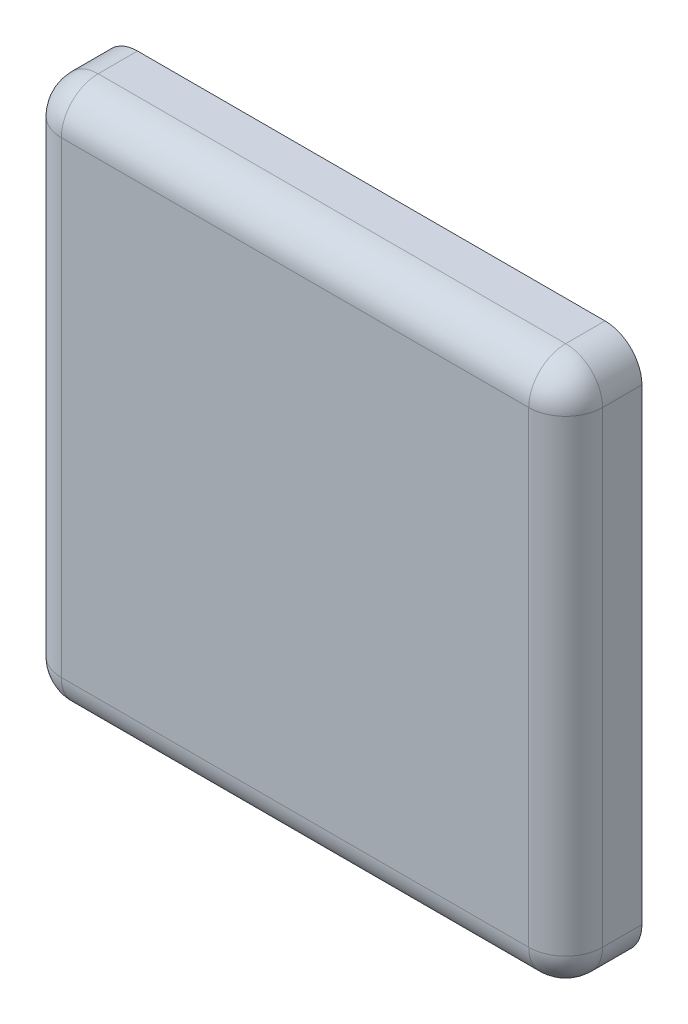
from build123d import *

# Parameters (mm, degrees)
SKETCH1_W      = 22
SKETCH1_H      = 22
EXTRUDE1_DEPTH = 3.1
FILLET1_R      = 1.5


with BuildPart() as part:
    # Sketch1 → Extrude1 (new body)
    with BuildSketch(Plane.XY):
        with Locations((11, 11)):
            Rectangle(SKETCH1_W, SKETCH1_H)
    extrude(amount=EXTRUDE1_DEPTH)

    # Fillet1
    fillet1_edges = [part.edges().sort_by_distance(p)[0] for p in [
        (22, 11, 3.1),
        (11, 22, 3.1),
        (0, 11, 3.1),
        (11, 0, 3.1),
        (0, 22, 1.55),
        (22, 22, 1.55),
        (22, 0, 1.55),
        (0, 0, 1.55),
    ]]
    fillet(fillet1_edges, radius=FILLET1_R)


solid = part.part
